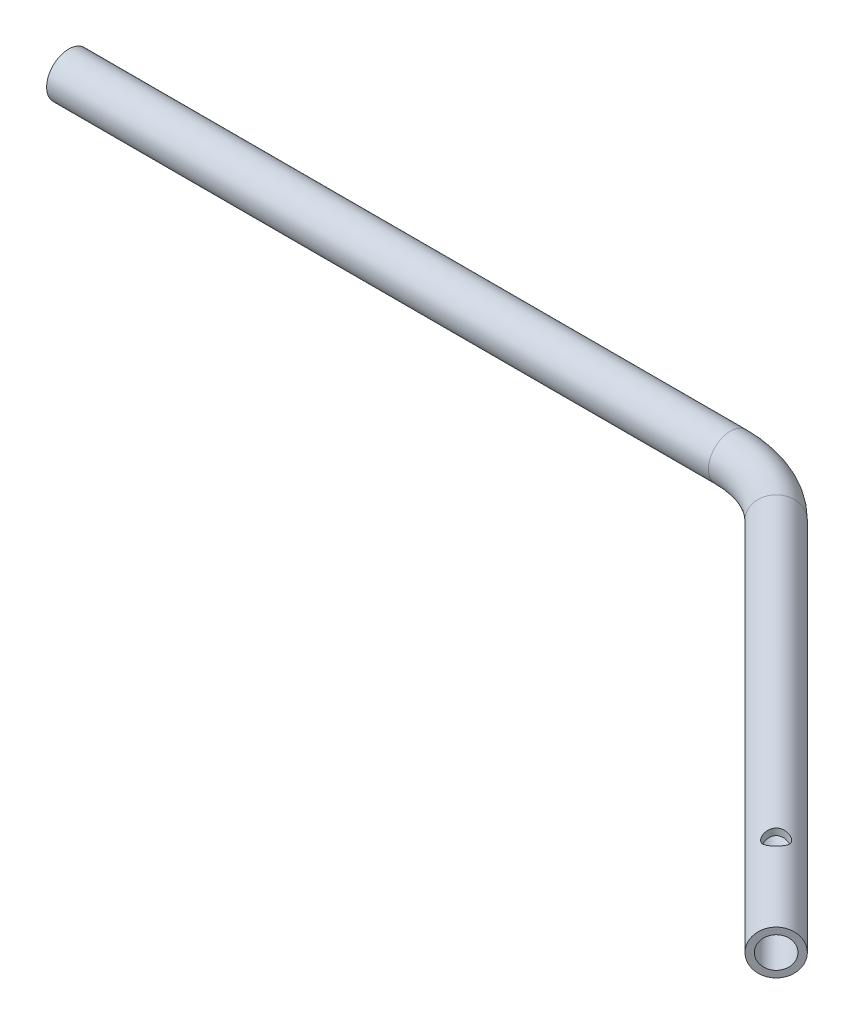
from build123d import *

# Parameters (mm, degrees)
SWEEP_THIN1_PROFILE_R   = 10
SWEEP_THIN1_PROFILE_R_2 = 7
SKETCH22_R              = 5
CUT_EXTRUDE1_DEPTH      = 542.256514583
CUT_EXTRUDE1_DEPTH_BACK = 542.256514583


with BuildPart() as part:
    # Sweep-Thin1: sweep along a path in Sketch1
    with BuildLine(Plane(origin=(0, 0, 0), x_dir=(1, 0, 0), z_dir=(0, 1, 0))) as sweep_thin1_path:
        Line((0, 0), (-169.705627485, 169.705627485))
        ThreePointArc((-169.705627485, 169.705627485), (-185.926794926, 180.544265051), (-205.060966544, 184.350288425))
        Line((-205.060966544, 184.350288425), (-505.060966544, 184.350288425))
    # Sweep-Thin1 profile (on start of the path) → Sweep-Thin1 (sweep)
    with BuildSketch(Plane(origin=(0, 0, 0), x_dir=(-0.7071067811865487, 0, 0.7071067811865465), z_dir=(-0.7071067811865465, 0, -0.7071067811865487))):
        Circle(SWEEP_THIN1_PROFILE_R)
        Circle(SWEEP_THIN1_PROFILE_R_2, mode=Mode.SUBTRACT)
    sweep(path=sweep_thin1_path.line)

    # Sketch22 → Cut-Extrude1 (cut, two sides)
    with BuildSketch(Plane(origin=(0, 0, 0), x_dir=(1, 0, 0), z_dir=(0, 1, 0))) as cut_extrude1_sk:
        with Locations(Location((-35.355339059, 35.355339059, 0), (0, 0, 270))):
            Circle(SKETCH22_R)
    extrude(amount=CUT_EXTRUDE1_DEPTH, mode=Mode.SUBTRACT)
    extrude(cut_extrude1_sk.sketch, amount=-CUT_EXTRUDE1_DEPTH_BACK, mode=Mode.SUBTRACT)


solid = part.part
